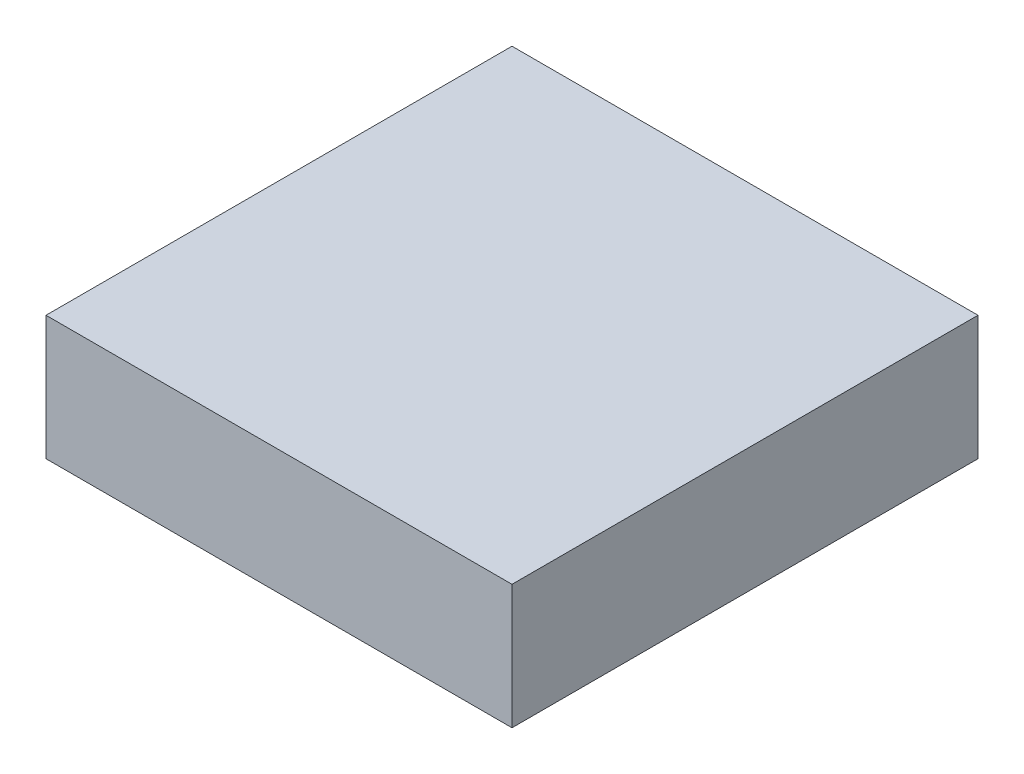
from build123d import *

# Parameters (mm, degrees)
SKETCH1_W           = 76.2
SKETCH1_H           = 76.2
BOSS_EXTRUDE3_DEPTH = 20.32
SHELL3_T            = 2.54


with BuildPart() as part:
    # Sketch1 → Boss-Extrude3 (new body)
    with BuildSketch(Plane(origin=(0, 0, 0), x_dir=(1, 0, 0), z_dir=(0, 1, 0))):
        Rectangle(SKETCH1_W, SKETCH1_H)
    extrude(amount=BOSS_EXTRUDE3_DEPTH)

    # Shell3 (no face opened: a closed hollow body)
    add(offset(amount=-SHELL3_T, mode=Mode.PRIVATE), mode=Mode.SUBTRACT)


solid = part.part
